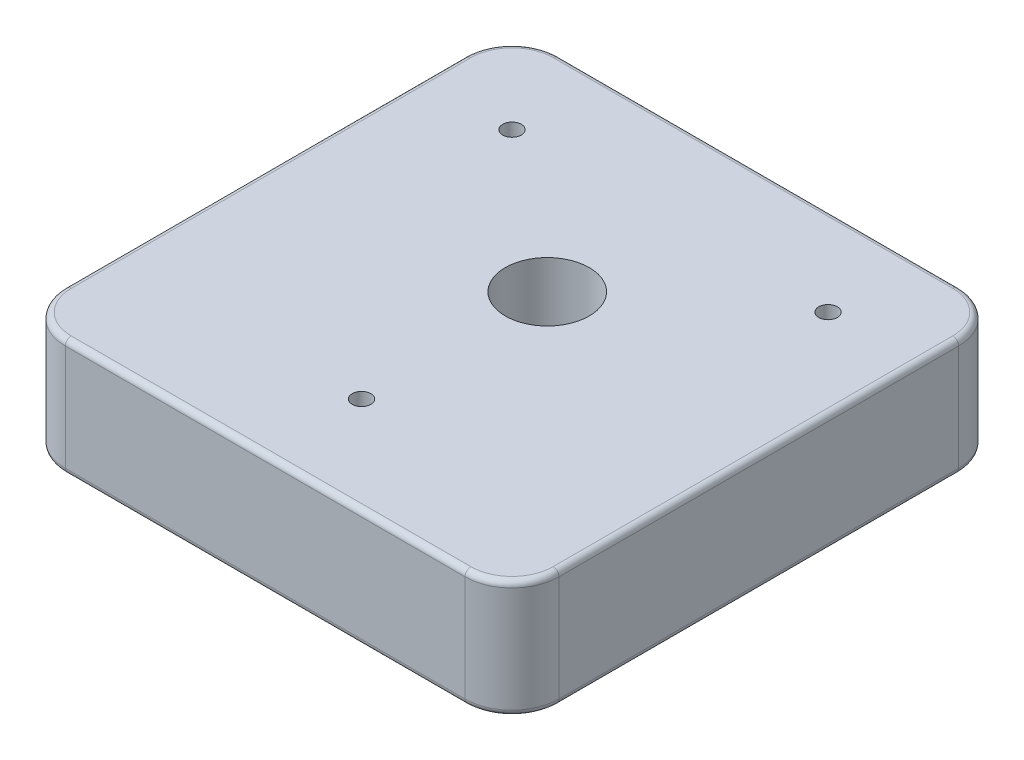
from build123d import *

# Parameters (mm, degrees)
SKETCH1_W                      = 42
SKETCH1_H                      = 42
EXTRUDE1_DEPTH                 = 10
SKETCH2_R                      = 3.18135
EXTRUDE2_DEPTH                 = 3.1877
F_1_4_CLEARANCE_HOLE1_D        = 7.14248
FILLET1_R                      = 4
FILLET2_R                      = 1.5875
F_1_16_0_0625_DIAMETER_HOLE1_D = 1.5875
FILLET3_R                      = 0.5


with BuildPart() as part:
    # Sketch1 → Extrude1 (new body)
    with BuildSketch(Plane(origin=(0, 0, 0), x_dir=(1, 0, 0), z_dir=(0, 1, 0))):
        Rectangle(SKETCH1_W, SKETCH1_H)
    extrude(amount=EXTRUDE1_DEPTH)

    # Sketch2 → Extrude2 (cut)
    with BuildSketch(Plane.XZ):
        with Locations(Location((-15, -15, 0), (0, 0, 270))):  # turned: the seam where the file's is
            Circle(SKETCH2_R)
        with Locations(Location((15, -15, 0), (0, 0, 270))):  # turned: the seam where the file's is
            Circle(SKETCH2_R)
        with Locations(Location((0, 15, 0), (0, 0, 270))):  # turned: the seam where the file's is
            Circle(SKETCH2_R)
    extrude(amount=-EXTRUDE2_DEPTH, mode=Mode.SUBTRACT)

    # 1/4 Clearance Hole1 (through all)
    with Locations(Plane(origin=(0, 0, -3), x_dir=(0, 0, -1), z_dir=(0, -1, 0))):
        with Locations((0, 0)):
            Hole(F_1_4_CLEARANCE_HOLE1_D / 2)

    # Fillet1
    fillet1_edges = [part.edges().sort_by_distance(p)[0] for p in [
        (-21, 5, -21),
        (21, 5, -21),
        (21, 5, 21),
        (-21, 5, 21),
    ]]
    fillet(fillet1_edges, radius=FILLET1_R)

    # Fillet2
    fillet2_edges = [part.edges().sort_by_distance(p)[0] for p in [
        (-15, 3.1877, -11.81865),
        (15, 3.1877, -11.81865),
        (0, 3.1877, 18.18135),
    ]]
    fillet(fillet2_edges, radius=FILLET2_R)

    # 1/16 (0.0625) Diameter Hole1 (through all)
    with Locations(Plane(origin=(0, 0, 12.8), x_dir=(0, 0, -1), z_dir=(0, -1, 0))):
        with Locations((0, 0), (26.244365081, -13.444365081), (26.244365081, 13.444365081)):
            Hole(F_1_16_0_0625_DIAMETER_HOLE1_D / 2)

    # Fillet3
    fillet3_edges = [part.edges().sort_by_distance(p)[0] for p in [
        (21, 0, 0),
        (21, 10, 0),
        (-21, 0, 0),
        (0, 0, -21),
        (0, 0, 21),
        (19.828427125, 0, -19.828427125),
        (-19.828427125, 0, -19.828427125),
        (-19.828427125, 0, 19.828427125),
        (19.828427125, 0, 19.828427125),
        (0, 10, 21),
        (-21, 10, 0),
        (0, 10, -21),
        (19.828427125, 10, -19.828427125),
        (-19.828427125, 10, -19.828427125),
        (-19.828427125, 10, 19.828427125),
        (19.828427125, 10, 19.828427125),
    ]]
    fillet(fillet3_edges, radius=FILLET3_R)


solid = part.part
